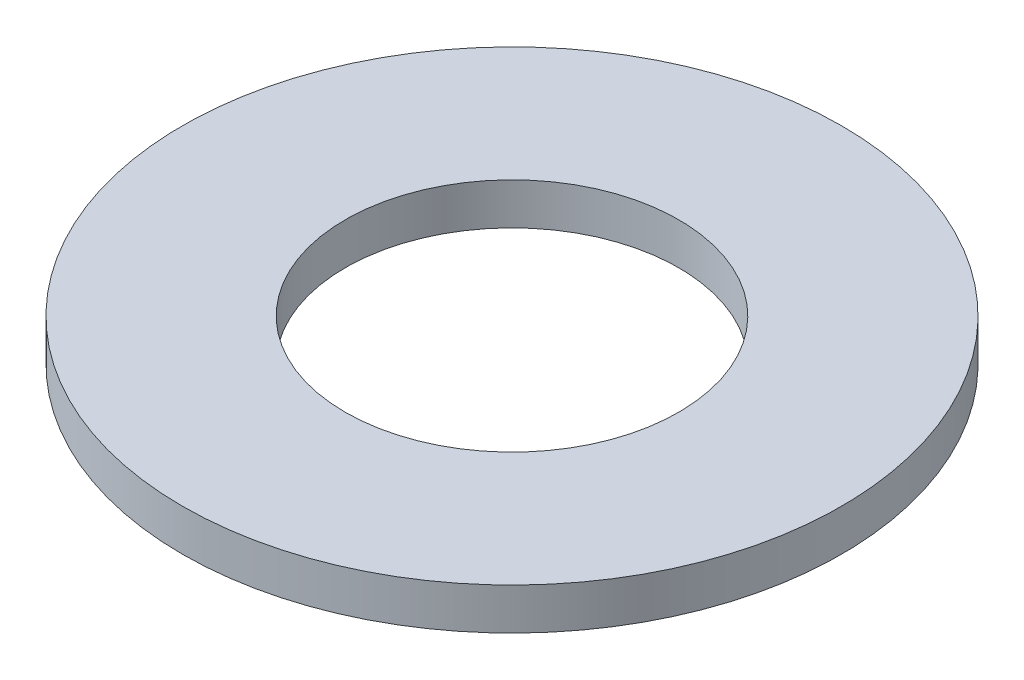
from build123d import *

# Parameters (mm, degrees)
SKETCH1_R           = 12.6746
SKETCH1_R_2         = 6.4135
BOSS_EXTRUDE1_DEPTH = 0.8001


with BuildPart() as part:
    # Sketch1 → Boss-Extrude1 (new body, symmetric)
    with BuildSketch(Plane(origin=(0, 0, 0), x_dir=(1, 0, 0), z_dir=(0, 1, 0))):
        Circle(SKETCH1_R)
        Circle(SKETCH1_R_2, mode=Mode.SUBTRACT)
    extrude(amount=BOSS_EXTRUDE1_DEPTH, both=True)


solid = part.part
